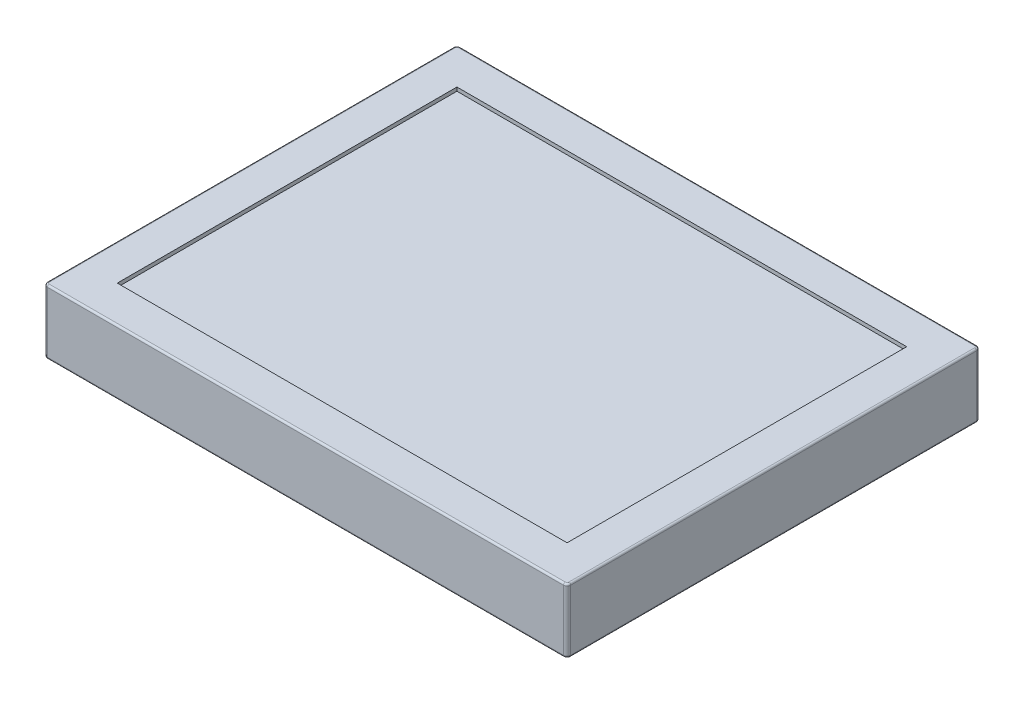
from build123d import *

# Parameters (mm, degrees)
SKETCH1_W           = 285
SKETCH1_H           = 225
BOSS_EXTRUDE1_DEPTH = 35
SKETCH2_W           = 245
SKETCH2_H           = 185
CUT_EXTRUDE1_DEPTH  = 2
FILLET1_R           = 2
FILLET2_R           = 1
FILLET3_R           = 1
SKETCH4_R           = 2
CUT_EXTRUDE2_DEPTH  = 2


with BuildPart() as part:
    # Sketch1 → Boss-Extrude1 (new body)
    with BuildSketch(Plane(origin=(0, 0, 0), x_dir=(1, 0, 0), z_dir=(0, 1, 0))):
        Rectangle(SKETCH1_W, SKETCH1_H)
    extrude(amount=BOSS_EXTRUDE1_DEPTH)

    # Sketch2 → Cut-Extrude1 (cut)
    with BuildSketch(Plane(origin=(0, 35, 0), x_dir=(1, 0, 0), z_dir=(0, 1, 0))):
        Rectangle(SKETCH2_W, SKETCH2_H)
    extrude(amount=-CUT_EXTRUDE1_DEPTH, mode=Mode.SUBTRACT)

    # Fillet1
    fillet1_edges = [part.edges().sort_by_distance(p)[0] for p in [
        (142.5, 17.5, 112.5),
        (-142.5, 17.5, 112.5),
        (-142.5, 17.5, -112.5),
        (142.5, 17.5, -112.5),
    ]]
    fillet(fillet1_edges, radius=FILLET1_R)

    # Fillet2
    fillet2_edges = [part.edges().sort_by_distance(p)[0] for p in [
        (-142.5, 35, 0),
        (0, 35, -112.5),
        (142.5, 35, 0),
        (0, 35, 112.5),
        (141.914213562, 35, 111.914213562),
        (141.914213562, 35, -111.914213562),
        (-141.914213562, 35, 111.914213562),
        (-141.914213562, 35, -111.914213562),
    ]]
    fillet(fillet2_edges, radius=FILLET2_R)

    # Fillet3
    fillet3_edges = [part.edges().sort_by_distance(p)[0] for p in [
        (-142.5, 0, 0),
        (142.5, 0, 0),
        (0, 0, 112.5),
        (0, 0, -112.5),
        (141.914213562, 0, 111.914213562),
        (141.914213562, 0, -111.914213562),
        (-141.914213562, 0, 111.914213562),
        (-141.914213562, 0, -111.914213562),
    ]]
    fillet(fillet3_edges, radius=FILLET3_R)

    # Sketch4 → Cut-Extrude2 (cut)
    with BuildSketch(Plane.XZ):
        with Locations((-24.748737342, 24.748737342)):
            Circle(SKETCH4_R)
        with Locations((-35.355339059, 35.355339059)):
            Circle(SKETCH4_R)
        with Locations((-45.961940777, 45.961940777)):
            Circle(SKETCH4_R)
        with Locations((24.748737342, 24.748737342)):
            Circle(SKETCH4_R)
        with Locations((35.355339059, 35.355339059)):
            Circle(SKETCH4_R)
        with Locations((45.961940777, 45.961940777)):
            Circle(SKETCH4_R)
        with Locations((24.748737342, -24.748737342)):
            Circle(SKETCH4_R)
        with Locations((35.355339059, -35.355339059)):
            Circle(SKETCH4_R)
        with Locations((45.961940777, -45.961940777)):
            Circle(SKETCH4_R)
        with Locations((-24.748737342, -24.748737342)):
            Circle(SKETCH4_R)
        with Locations((-35.355339059, -35.355339059)):
            Circle(SKETCH4_R)
        with Locations((-45.961940777, -45.961940777)):
            Circle(SKETCH4_R)
    extrude(amount=-CUT_EXTRUDE2_DEPTH, mode=Mode.SUBTRACT)


solid = part.part
